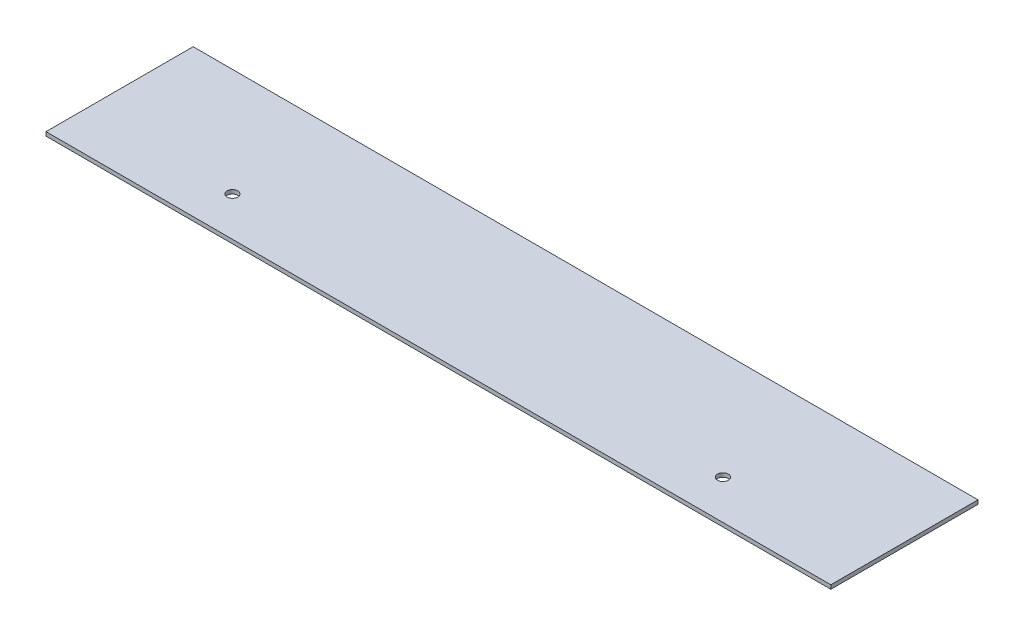
from build123d import *

# Parameters (mm, degrees)
SKETCH1_W           = 160
SKETCH1_H           = 30
SKETCH1_R           = 1.1
BOSS_EXTRUDE1_DEPTH = 0.8


with BuildPart() as part:
    # Sketch1 → Boss-Extrude1 (new body)
    with BuildSketch(Plane(origin=(0, 0, 0), x_dir=(1, 0, 0), z_dir=(0, 1, 0))):
        with Locations((80, 15)):
            Rectangle(SKETCH1_W, SKETCH1_H)
        with Locations((30, 8)):
            Circle(SKETCH1_R, mode=Mode.SUBTRACT)
        with Locations((130, 8)):
            Circle(SKETCH1_R, mode=Mode.SUBTRACT)
    extrude(amount=BOSS_EXTRUDE1_DEPTH)


solid = part.part
